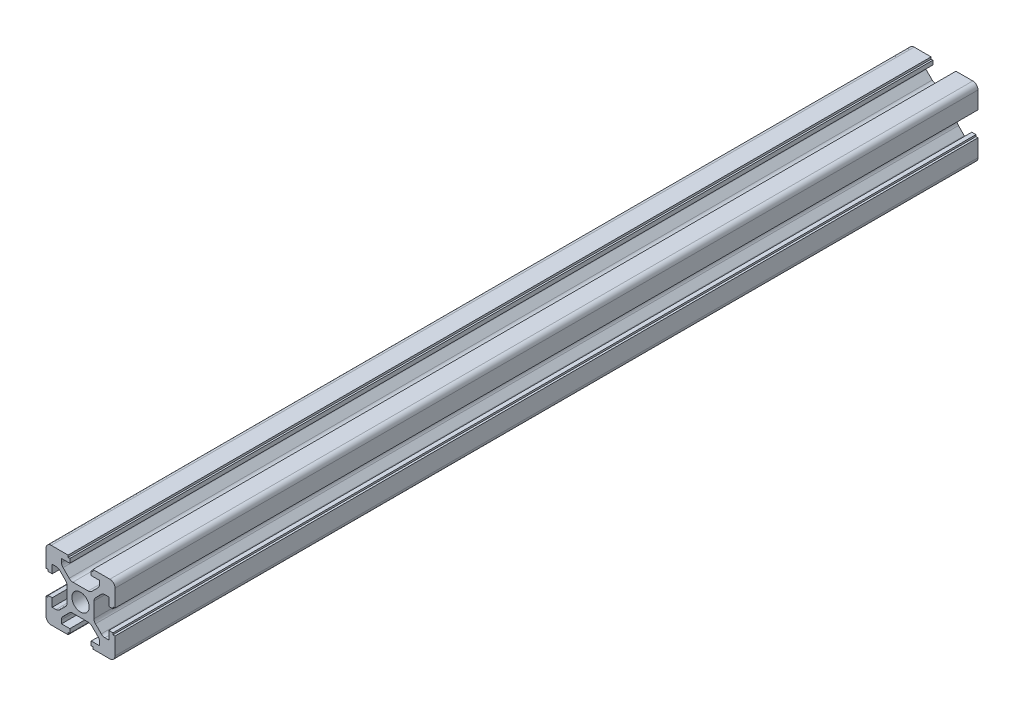
from build123d import *

# Parameters (mm, degrees)
SKETCH1_R           = 2.5
BOSS_EXTRUDE1_DEPTH = 250


with BuildPart() as part:
    # Sketch1 → Boss-Extrude1 (new body)
    with BuildSketch(Plane.XY):
        with BuildLine():
            Line((-3.6, -10), (-8.5, -10))
            ThreePointArc((-8.5, -10), (-9.560660172, -9.560660172), (-10, -8.5))
            Line((-10, -8.5), (-10, -3.5))
            Line((-10, -3.5), (-9.4, -3.5))
            Line((-9.4, -3.5), (-9.4, -3))
            Line((-9.4, -3), (-8.2, -3))
            Line((-8.2, -3), (-8.2, -5.4))
            Line((-8.2, -5.4), (-7.081980515, -5.4))
            ThreePointArc((-7.081980515, -5.4), (-6.507955367, -5.285819299), (-6.021320344, -4.960660172))
            Line((-6.021320344, -4.960660172), (-4.339339828, -3.278679656))
            ThreePointArc((-4.339339828, -3.278679656), (-4.014180701, -2.792044633), (-3.9, -2.218019485))
            Line((-3.9, -2.218019485), (-3.9, 2.218019485))
            ThreePointArc((-3.9, 2.218019485), (-4.014180701, 2.792044633), (-4.339339828, 3.278679656))
            Line((-4.339339828, 3.278679656), (-6.021320344, 4.960660172))
            ThreePointArc((-6.021320344, 4.960660172), (-6.507955367, 5.285819299), (-7.081980515, 5.4))
            Line((-7.081980515, 5.4), (-8.2, 5.4))
            Line((-8.2, 5.4), (-8.2, 3))
            Line((-8.2, 3), (-9.4, 3))
            Line((-9.4, 3), (-9.4, 3.5))
            Line((-9.4, 3.5), (-10, 3.5))
            Line((-10, 3.5), (-10, 8.5))
            ThreePointArc((-10, 8.5), (-9.560660172, 9.560660172), (-8.5, 10))
            Line((-8.5, 10), (-3.6, 10))
            Line((-3.6, 10), (-3.6, 9.4))
            Line((-3.6, 9.4), (-3.1, 9.4))
            Line((-3.1, 9.4), (-3.1, 8.2))
            Line((-3.1, 8.2), (-5.5, 8.2))
            Line((-5.5, 8.2), (-5.5, 7.181980515))
            ThreePointArc((-5.5, 7.181980515), (-5.385819299, 6.607955367), (-5.060660172, 6.121320344))
            Line((-5.060660172, 6.121320344), (-3.278679656, 4.339339828))
            ThreePointArc((-3.278679656, 4.339339828), (-2.792044633, 4.014180701), (-2.218019485, 3.9))
            Line((-2.218019485, 3.9), (2.218019485, 3.9))
            ThreePointArc((2.218019485, 3.9), (2.792044633, 4.014180701), (3.278679656, 4.339339828))
            Line((3.278679656, 4.339339828), (5.060660172, 6.121320344))
            ThreePointArc((5.060660172, 6.121320344), (5.385819299, 6.607955367), (5.5, 7.181980515))
            Line((5.5, 7.181980515), (5.5, 8.2))
            Line((5.5, 8.2), (3.1, 8.2))
            Line((3.1, 8.2), (3.1, 9.4))
            Line((3.1, 9.4), (3.6, 9.4))
            Line((3.6, 9.4), (3.6, 10))
            Line((3.6, 10), (8.5, 10))
            ThreePointArc((8.5, 10), (9.560660172, 9.560660172), (10, 8.5))
            Line((10, 8.5), (10, 3.5))
            Line((10, 3.5), (9.4, 3.5))
            Line((9.4, 3.5), (9.4, 3))
            Line((9.4, 3), (8.2, 3))
            Line((8.2, 3), (8.2, 5.4))
            Line((8.2, 5.4), (7.081980515, 5.4))
            ThreePointArc((7.081980515, 5.4), (6.507955367, 5.285819299), (6.021320344, 4.960660172))
            Line((6.021320344, 4.960660172), (4.339339828, 3.278679656))
            ThreePointArc((4.339339828, 3.278679656), (4.014180701, 2.792044633), (3.9, 2.218019485))
            Line((3.9, 2.218019485), (3.9, -2.218019485))
            ThreePointArc((3.9, -2.218019485), (4.014180701, -2.792044633), (4.339339828, -3.278679656))
            Line((4.339339828, -3.278679656), (6.021320344, -4.960660172))
            ThreePointArc((6.021320344, -4.960660172), (6.507955367, -5.285819299), (7.081980515, -5.4))
            Line((7.081980515, -5.4), (8.2, -5.4))
            Line((8.2, -5.4), (8.2, -3))
            Line((8.2, -3), (9.4, -3))
            Line((9.4, -3), (9.4, -3.5))
            Line((9.4, -3.5), (10, -3.5))
            Line((10, -3.5), (10, -8.5))
            ThreePointArc((10, -8.5), (9.560660172, -9.560660172), (8.5, -10))
            Line((8.5, -10), (3.6, -10))
            Line((3.6, -10), (3.6, -9.4))
            Line((3.6, -9.4), (3.1, -9.4))
            Line((3.1, -9.4), (3.1, -8.2))
            Line((3.1, -8.2), (5.5, -8.2))
            Line((5.5, -8.2), (5.5, -7.181980515))
            ThreePointArc((5.5, -7.181980515), (5.385819299, -6.607955367), (5.060660172, -6.121320344))
            Line((5.060660172, -6.121320344), (3.278679656, -4.339339828))
            ThreePointArc((3.278679656, -4.339339828), (2.792044633, -4.014180701), (2.218019485, -3.9))
            Line((2.218019485, -3.9), (-2.218019485, -3.9))
            ThreePointArc((-2.218019485, -3.9), (-2.792044633, -4.014180701), (-3.278679656, -4.339339828))
            Line((-3.278679656, -4.339339828), (-5.060660172, -6.121320344))
            ThreePointArc((-5.060660172, -6.121320344), (-5.385819299, -6.607955367), (-5.5, -7.181980515))
            Line((-5.5, -7.181980515), (-5.5, -8.2))
            Line((-5.5, -8.2), (-3.1, -8.2))
            Line((-3.1, -8.2), (-3.1, -9.4))
            Line((-3.1, -9.4), (-3.6, -9.4))
            Line((-3.6, -9.4), (-3.6, -10))
        make_face()
        Circle(SKETCH1_R, mode=Mode.SUBTRACT)
    extrude(amount=BOSS_EXTRUDE1_DEPTH)


solid = part.part
